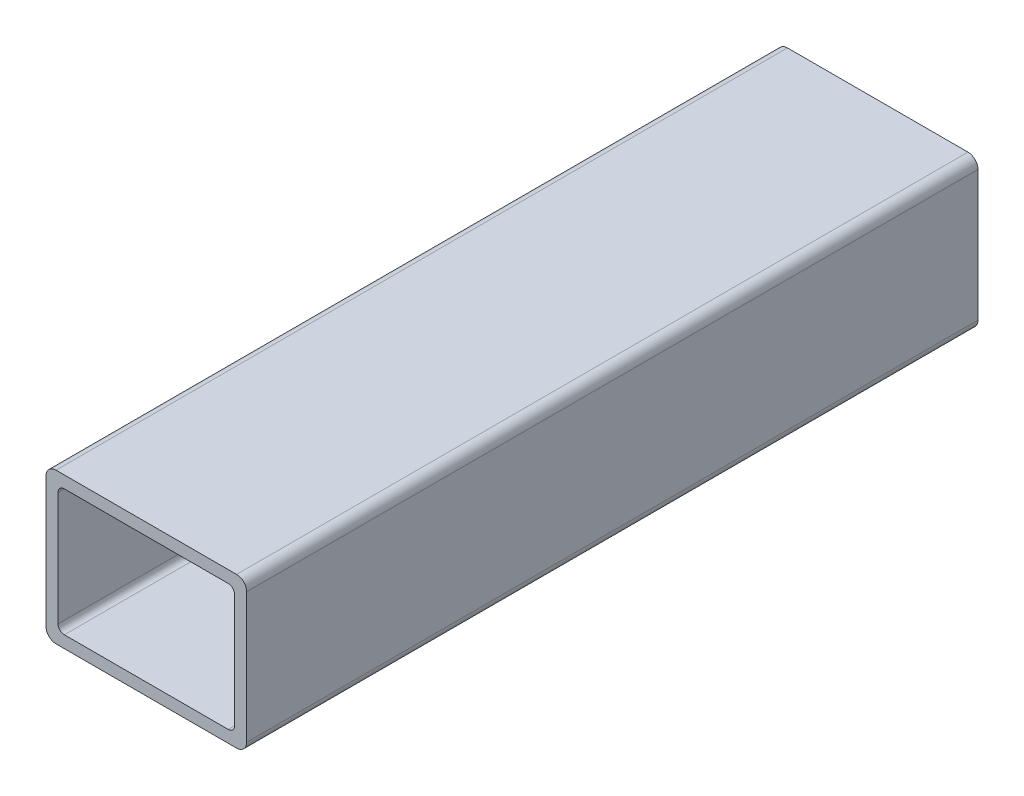
from build123d import *

# Parameters (mm, degrees)
BOSS_EXTRUDE1_DEPTH = 185.21934


with BuildPart() as part:
    # Sketch4 → Boss-Extrude1 (new body)
    with BuildSketch(Plane.XY):
        with BuildLine():
            Line((25.4, -16.51), (25.4, 16.51))
            ThreePointArc((25.4, 16.51), (24.656051224, 18.306051224), (22.86, 19.05))
            Line((22.86, 19.05), (-22.86, 19.05))
            ThreePointArc((-22.86, 19.05), (-24.656051224, 18.306051224), (-25.4, 16.51))
            Line((-25.4, 16.51), (-25.4, -16.51))
            ThreePointArc((-25.4, -16.51), (-24.656051224, -18.306051224), (-22.86, -19.05))
            Line((-22.86, -19.05), (22.86, -19.05))
            ThreePointArc((22.86, -19.05), (24.656051224, -18.306051224), (25.4, -16.51))
        make_face()
        with BuildLine():
            Line((22.352, 14.4018), (22.352, -14.4018))
            ThreePointArc((22.352, -14.4018), (21.883312271, -15.533312271), (20.7518, -16.002))
            Line((20.7518, -16.002), (-20.7518, -16.002))
            ThreePointArc((-20.7518, -16.002), (-21.883312271, -15.533312271), (-22.352, -14.4018))
            Line((-22.352, -14.4018), (-22.352, 14.4018))
            ThreePointArc((-22.352, 14.4018), (-21.883312271, 15.533312271), (-20.7518, 16.002))
            Line((-20.7518, 16.002), (20.7518, 16.002))
            ThreePointArc((20.7518, 16.002), (21.883312271, 15.533312271), (22.352, 14.4018))
        make_face(mode=Mode.SUBTRACT)
    extrude(amount=BOSS_EXTRUDE1_DEPTH)


solid = part.part
